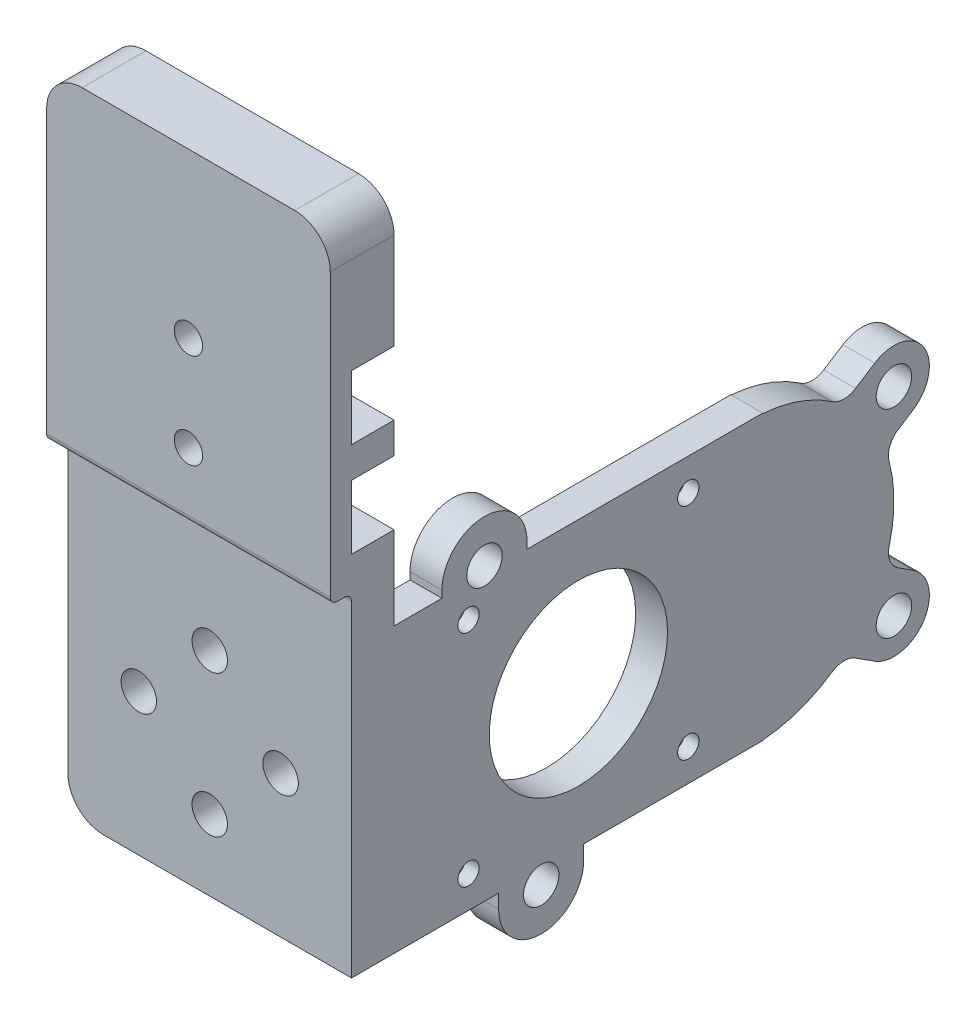
from build123d import *

# Parameters (mm, degrees)
SKETCH2_W            = 40
SKETCH2_H            = 40
SKETCH2_R            = 2.5
BOSS_EXTRUDE1_DEPTH  = 6
SKETCH3_W            = 4.5
SKETCH3_H            = 40
BOSS_EXTRUDE2_DEPTH  = 52
CUT_EXTRUDE1_REACH   = 6.5
SKETCH4_R            = 12.573151632
SKETCH4_R_2          = 1.5
SKETCH5_R            = 4.5
CUT_EXTRUDE2_DEPTH   = 1.5
SKETCH6_R            = 3
CUT_EXTRUDE3_DEPTH   = 2.5
FILLET1_R            = 5
SKETCH11_R           = 2.5
BOSS_EXTRUDE6_DEPTH  = 4.5
FILLET2_R            = 3
SKETCH9_R            = 2.5
BOSS_EXTRUDE15_DEPTH = 4.5
SKETCH24_R           = 2.5
CUT_EXTRUDE11_DEPTH  = 4.5
SKETCH15_R           = 3
CUT_EXTRUDE12_DEPTH  = 2.5
SKETCH25_W           = 40
SKETCH25_H           = 9
BOSS_EXTRUDE16_DEPTH = 52.75
SKETCH28_W           = 40
SKETCH28_H           = 2
CUT_EXTRUDE15_DEPTH  = 3
SKETCH33_W           = 40
SKETCH33_H           = 5
CUT_EXTRUDE18_DEPTH  = 3
FILLET7_R            = 1
FILLET8_R            = 5
SKETCH31_W           = 40
SKETCH31_H           = 9.0424
CUT_EXTRUDE16_DEPTH  = 6
SKETCH32_R           = 2
CUT_EXTRUDE17_DEPTH  = 4


with BuildPart() as part:
    # Sketch2 → Boss-Extrude1 (new body)
    with BuildSketch(Plane.XY):
        Rectangle(SKETCH2_W, SKETCH2_H)
        with Locations((0, 10)):
            Circle(SKETCH2_R, mode=Mode.SUBTRACT)
        with Locations((0, -10)):
            Circle(SKETCH2_R, mode=Mode.SUBTRACT)
        with Locations((-10, 0)):
            Circle(SKETCH2_R, mode=Mode.SUBTRACT)
        with Locations((10, 0)):
            Circle(SKETCH2_R, mode=Mode.SUBTRACT)
    extrude(amount=-BOSS_EXTRUDE1_DEPTH)

    # Sketch3 → Boss-Extrude2 (add)
    with BuildSketch(Plane(origin=(0, 0, -6), x_dir=(-1, 0, 0), z_dir=(0, 0, -1))):
        with Locations((-17.75, 0)):
            Rectangle(SKETCH3_W, SKETCH3_H)
    extrude(amount=BOSS_EXTRUDE2_DEPTH)

    # Sketch4 → Cut-Extrude1 (cut, up to next)
    with BuildSketch(Plane.ZY.offset(-15.5), mode=Mode.PRIVATE) as cut_extrude1_sk1:
        with Locations((-32, 0)):
            Circle(SKETCH4_R)
    cut_extrude1_tool1 = extrude(cut_extrude1_sk1.sketch, amount=-CUT_EXTRUDE1_REACH, mode=Mode.PRIVATE) & part.part
    add(cut_extrude1_tool1.solids().sort_by_distance((15.5, 0, -32))[0], mode=Mode.SUBTRACT)
    # Sketch4 → Cut-Extrude1 (cut, up to next)
    with BuildSketch(Plane.ZY.offset(-15.5), mode=Mode.PRIVATE) as cut_extrude1_sk2:
        with Locations((-16.5, 15.5)):
            Circle(SKETCH4_R_2)
    cut_extrude1_tool2 = extrude(cut_extrude1_sk2.sketch, amount=-CUT_EXTRUDE1_REACH, mode=Mode.PRIVATE) & part.part
    add(cut_extrude1_tool2.solids().sort_by_distance((15.5, 15.5, -16.5))[0], mode=Mode.SUBTRACT)
    # Sketch4 → Cut-Extrude1 (cut, up to next)
    with BuildSketch(Plane.ZY.offset(-15.5), mode=Mode.PRIVATE) as cut_extrude1_sk3:
        with Locations((-16.5, -15.5)):
            Circle(SKETCH4_R_2)
    cut_extrude1_tool3 = extrude(cut_extrude1_sk3.sketch, amount=-CUT_EXTRUDE1_REACH, mode=Mode.PRIVATE) & part.part
    add(cut_extrude1_tool3.solids().sort_by_distance((15.5, -15.5, -16.5))[0], mode=Mode.SUBTRACT)
    # Sketch4 → Cut-Extrude1 (cut, up to next)
    with BuildSketch(Plane.ZY.offset(-15.5), mode=Mode.PRIVATE) as cut_extrude1_sk4:
        with Locations((-47.5, -15.5)):
            Circle(SKETCH4_R_2)
    cut_extrude1_tool4 = extrude(cut_extrude1_sk4.sketch, amount=-CUT_EXTRUDE1_REACH, mode=Mode.PRIVATE) & part.part
    add(cut_extrude1_tool4.solids().sort_by_distance((15.5, -15.5, -47.5))[0], mode=Mode.SUBTRACT)
    # Sketch4 → Cut-Extrude1 (cut, up to next)
    with BuildSketch(Plane.ZY.offset(-15.5), mode=Mode.PRIVATE) as cut_extrude1_sk5:
        with Locations((-47.5, 15.5)):
            Circle(SKETCH4_R_2)
    cut_extrude1_tool5 = extrude(cut_extrude1_sk5.sketch, amount=-CUT_EXTRUDE1_REACH, mode=Mode.PRIVATE) & part.part
    add(cut_extrude1_tool5.solids().sort_by_distance((15.5, 15.5, -47.5))[0], mode=Mode.SUBTRACT)

    # Sketch5 → Cut-Extrude2 (cut)
    with BuildSketch(Plane(origin=(0, 0, -6), x_dir=(-1, 0, 0), z_dir=(0, 0, -1))):
        with Locations((0, 10)):
            Circle(SKETCH5_R)
        with Locations((10, 0)):
            Circle(SKETCH5_R)
        with Locations((0, -10)):
            Circle(SKETCH5_R)
        with Locations((-10, 0)):
            Circle(SKETCH5_R)
    extrude(amount=-CUT_EXTRUDE2_DEPTH, mode=Mode.SUBTRACT)

    # Sketch6 → Cut-Extrude3 (cut)
    with BuildSketch(Plane.ZY.offset(-15.5)):
        with Locations((-16.5, 15.5)):
            Circle(SKETCH6_R)
        with Locations((-47.5, 15.5)):
            Circle(SKETCH6_R)
        with Locations((-47.5, -15.5)):
            Circle(SKETCH6_R)
        with Locations((-16.5, -15.5)):
            Circle(SKETCH6_R)
    extrude(amount=-CUT_EXTRUDE3_DEPTH, mode=Mode.SUBTRACT)

    # Fillet1
    fillet1_edges = [part.edges().sort_by_distance(p)[0] for p in [
        (-20, -20, -3),
    ]]
    fillet(fillet1_edges, radius=FILLET1_R)

    # Sketch11 → Boss-Extrude6 (add)
    with BuildSketch(Plane.ZY.offset(-15.5)):
        with BuildLine():
            Line((-58, -19.943670675), (-58, 19.943670675))
            ThreePointArc((-58, 19.943670675), (-64.026515977, 18.5297479), (-69.332027993, 15.34076457))
            ThreePointArc((-69.332027993, 15.34076457), (-72.76360296, 11.640241353), (-75.159610133, 7.198538025))
            ThreePointArc((-75.159610133, 7.198538025), (-76.5, 0), (-75.159610133, -7.198538025))
            ThreePointArc((-75.159610133, -7.198538025), (-72.76360296, -11.640241353), (-69.332027993, -15.34076457))
            ThreePointArc((-69.332027993, -15.34076457), (-64.026515977, -18.5297479), (-58, -19.943670675))
        make_face()
        with BuildLine():
            ThreePointArc((-75.159610133, 7.198538025), (-72.76360296, 11.640241353), (-69.332027993, 15.34076457))
            Line((-69.332027993, 15.34076457), (-73.799349609, 18.20790773))
            ThreePointArc((-73.799349609, 18.20790773), (-80.70790773, 16.700650391), (-79.200650391, 9.79209227))
            Line((-79.200650391, 9.79209227), (-75.159610133, 7.198538025))
        make_face()
        with Locations((-76.5, 14)):
            Circle(SKETCH11_R, mode=Mode.SUBTRACT)
        with BuildLine():
            Line((-73.799349609, -18.20790773), (-69.332027993, -15.34076457))
            ThreePointArc((-69.332027993, -15.34076457), (-72.76360296, -11.640241353), (-75.159610133, -7.198538025))
            Line((-75.159610133, -7.198538025), (-79.200650391, -9.79209227))
            ThreePointArc((-79.200650391, -9.79209227), (-80.70790773, -16.700650391), (-73.799349609, -18.20790773))
        make_face()
        with Locations((-76.5, -14)):
            Circle(SKETCH11_R, mode=Mode.SUBTRACT)
    extrude(amount=-BOSS_EXTRUDE6_DEPTH)

    # Fillet2
    fillet2_edges = [part.edges().sort_by_distance(p)[0] for p in [
        (17.75, -15.34076457, -69.332027993),
        (17.75, -7.198538025, -75.159610133),
        (17.75, 7.198538025, -75.159610133),
        (17.75, 15.34076457, -69.332027993),
    ]]
    fillet(fillet2_edges, radius=FILLET2_R)

    # Sketch9 → Boss-Extrude15 (add)
    with BuildSketch(Plane.ZY.offset(-15.5)):
        with BuildLine():
            Line((-32.75, -22), (-32.75, -18.434411342))
            Line((-32.75, -18.434411342), (-20.75, -18.434411342))
            Line((-20.75, -18.434411342), (-20.75, -22))
            ThreePointArc((-20.75, -22), (-26.75, -28), (-32.75, -22))
        make_face()
        with Locations((-26.75, -22)):
            Circle(SKETCH9_R, mode=Mode.SUBTRACT)
        with BuildLine():
            Line((-24.75, 21), (-24.75, 17.603718698))
            Line((-24.75, 17.603718698), (-12.75, 17.603718698))
            Line((-12.75, 17.603718698), (-12.75, 21))
            ThreePointArc((-12.75, 21), (-18.75, 27), (-24.75, 21))
        make_face()
        with Locations((-18.75, 21)):
            Circle(SKETCH9_R, mode=Mode.SUBTRACT)
    extrude(amount=-BOSS_EXTRUDE15_DEPTH)

    # Sketch24 → Cut-Extrude11 (cut)
    with BuildSketch(Plane.ZY.offset(-15.5)):
        with Locations((-18.75, 21)):
            Circle(SKETCH24_R)
        with Locations((-26.75, -22)):
            Circle(SKETCH24_R)
    extrude(amount=-CUT_EXTRUDE11_DEPTH, mode=Mode.SUBTRACT)

    # Sketch15 → Cut-Extrude12 (cut)
    with BuildSketch(Plane.ZY.offset(-15.5)):
        with Locations((-16.5, 15.5)):
            Circle(SKETCH15_R)
    extrude(amount=-CUT_EXTRUDE12_DEPTH, mode=Mode.SUBTRACT)

    # Sketch25 → Boss-Extrude16 (add)
    with BuildSketch(Plane(origin=(0, 20, 0), x_dir=(1, 0, 0), z_dir=(0, 1, 0))):
        with Locations((0, 1.5)):
            Rectangle(SKETCH25_W, SKETCH25_H)
    extrude(amount=BOSS_EXTRUDE16_DEPTH)

    # Sketch28 → Cut-Extrude15 (cut)
    with BuildSketch(Plane.XY.offset(3)):
        with Locations((0, 21)):
            Rectangle(SKETCH28_W, SKETCH28_H)
    extrude(amount=-CUT_EXTRUDE15_DEPTH, mode=Mode.SUBTRACT)

    # Sketch33 → Cut-Extrude18 (cut)
    with BuildSketch(Plane.XY.offset(3)):
        with Locations((0, 24.5)):
            Rectangle(SKETCH33_W, SKETCH33_H)
    extrude(amount=-CUT_EXTRUDE18_DEPTH, mode=Mode.SUBTRACT)

    # Fillet7
    fillet7_edges = [part.edges().sort_by_distance(p)[0] for p in [
        (0, 27, 3),
        (0, 27, 0),
    ]]
    fillet(fillet7_edges, radius=FILLET7_R)

    # Fillet8
    fillet8_edges = [part.edges().sort_by_distance(p)[0] for p in [
        (20, 72.75, -1.5),
        (-20, 72.75, -1.5),
    ]]
    fillet(fillet8_edges, radius=FILLET8_R)

    # Sketch31 → Cut-Extrude16 (cut)
    with BuildSketch(Plane(origin=(0, 0, -6), x_dir=(-1, 0, 0), z_dir=(0, 0, -1))):
        with Locations((0, 36.2712)):
            Rectangle(SKETCH31_W, SKETCH31_H)
        with Locations((0, 49.6636)):
            Rectangle(SKETCH31_W, SKETCH31_H)
    extrude(amount=-CUT_EXTRUDE16_DEPTH, mode=Mode.SUBTRACT)

    # Sketch32 → Cut-Extrude17 (cut, through all)
    with BuildSketch(Plane(origin=(0, 0, 0), x_dir=(-1, 0, 0), z_dir=(0, 0, -1))):
        with Locations((0, 49.6636)):
            Circle(SKETCH32_R)
        with Locations((0, 36.2712)):
            Circle(SKETCH32_R)
    extrude(amount=-CUT_EXTRUDE17_DEPTH, mode=Mode.SUBTRACT)


solid = part.part
